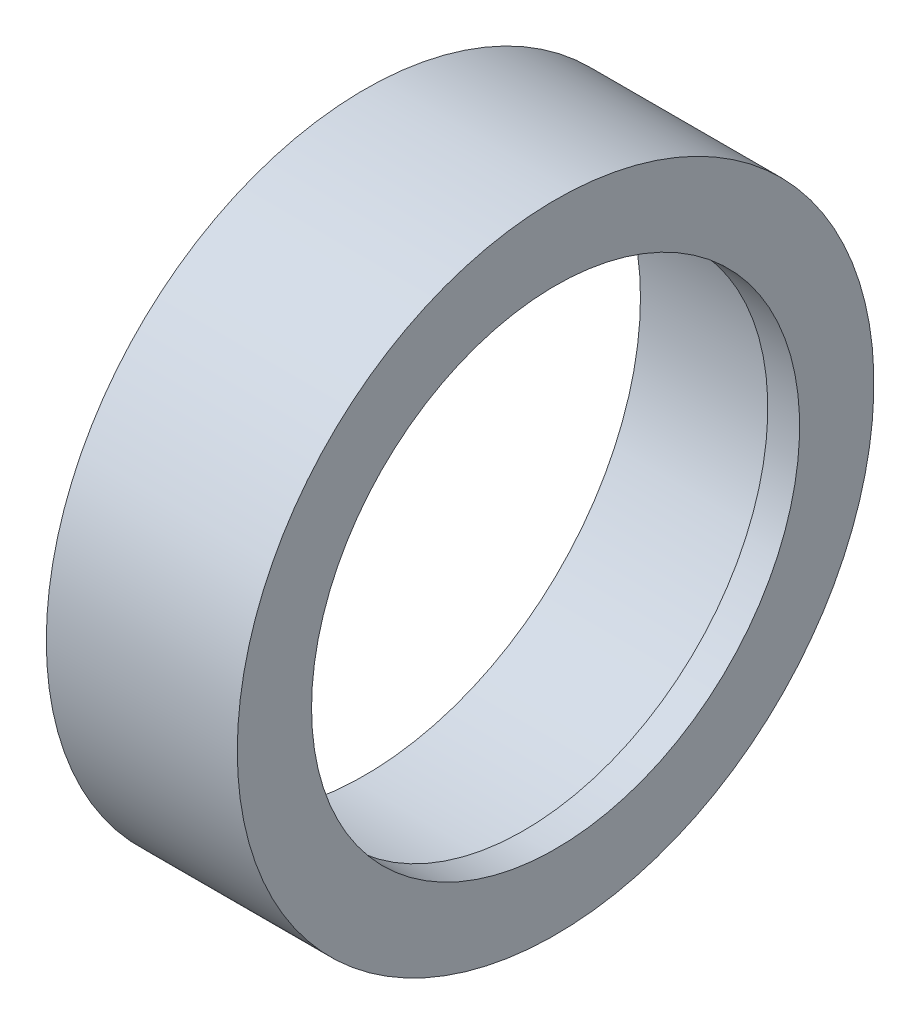
from build123d import *


with BuildPart() as part:
    # Sketch 2 → Повернуть1 (revolve)
    with BuildSketch(Plane.XY):
        Polygon((-15, 26), (-15, 30), (3, 30), (3, 23), (0, 23), (0, 26), align=None)
    revolve(axis=Axis((-1000, 0, 0), (1, 0, 0)))


solid = part.part
